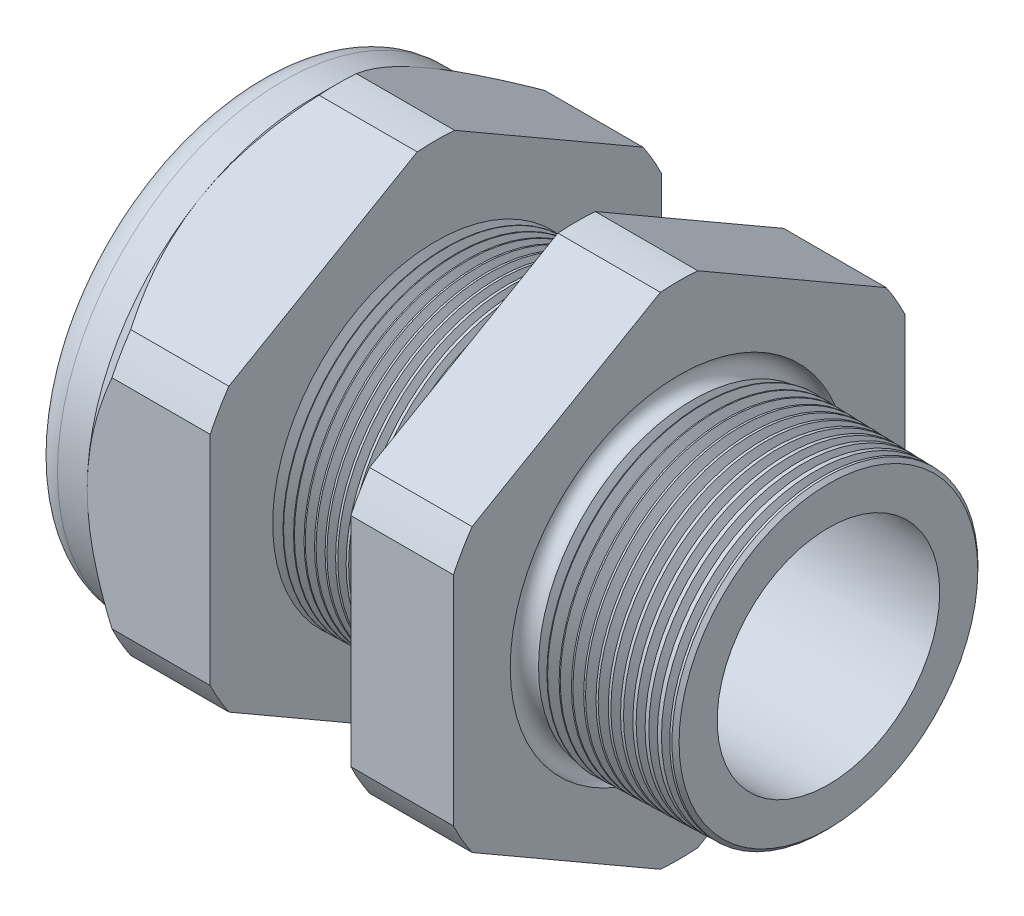
from build123d import *

# Parameters (mm, degrees)
SKETCH12_OUTSIDE_W = 88.514
SKETCH12_OUTSIDE_H = 88.514
CUT_EXTRUDE2_DEPTH = 38.71
FILLET4_R          = 2.032
SKETCH19_OUTSIDE_W = 55.962
SKETCH19_OUTSIDE_H = 59.594
SKETCH19_OUTSIDE_R = 16.51
CUT_EXTRUDE3_DEPTH = 3.99796
CUT_EXTRUDE3_DRAFT = -45
CHAMFER1_SIZE      = 0.260919487
CHAMFER1_SIZE2     = 0.254
SKETCH21_R         = 9.017
PLUG_DEPTH         = 8.89
SKETCH22_R         = 8.763
CUT_EXTRUDE4_DEPTH = 0.508
SKETCH27_R         = 3.683
PLUGHOLES_DEPTH    = 42.402
CIRPATTERN1_COUNT  = 2
LPATTERN1_COUNT    = 14
LPATTERN1_PITCH    = 0.762
LPATTERN2_COUNT    = 12
LPATTERN2_PITCH    = 0.889
SKETCH32_R         = 0.889


with BuildPart() as part:
    # Sketch10 → Revolve2 (revolve)
    with BuildSketch(Plane.XY, mode=Mode.PRIVATE) as revolve2_sk:
        Polygon((-38.862, 9.017), (-25.662, 9.017), (3.048, 8.138202192), (3.048, 11.186202192), (-7.874, 11.472204827), (-7.874, 33.02), (-15.374, 33.02), (-15.374, 11.668599239), (-25.662, 11.938), (-25.662, 33.02), (-34.662, 33.02), (-34.662, 16.51), (-38.862, 16.51), align=None)
    revolve(revolve2_sk.sketch.rotate(Axis((0, 0, 0), (-1, 0, 0)), 90), axis=Axis((0, 0, 0), (-1, 0, 0)))  # turned: the seam where the file's is

    # Sketch12 outside → Cut-Extrude2 (cut, through all)
    with BuildSketch(Plane.ZY.offset(34.662)):
        Rectangle(SKETCH12_OUTSIDE_W, SKETCH12_OUTSIDE_H)
        with BuildLine():
            Line((-1.366648898, 18.27507078), (-15.143351102, 10.321088053))
            ThreePointArc((-15.143351102, 10.321088053), (-15.870868152, 9.16305), (-16.51, 7.953982726))
            Line((-16.51, 7.953982726), (-16.51, -7.953982726))
            ThreePointArc((-16.51, -7.953982726), (-15.870868152, -9.16305), (-15.143351102, -10.321088053))
            Line((-15.143351102, -10.321088053), (-1.366648898, -18.27507078))
            ThreePointArc((-1.366648898, -18.27507078), (0, -18.3261), (1.366648898, -18.27507078))
            Line((1.366648898, -18.27507078), (15.143351102, -10.321088053))
            ThreePointArc((15.143351102, -10.321088053), (15.870868152, -9.16305), (16.51, -7.953982726))
            Line((16.51, -7.953982726), (16.51, 7.953982726))
            ThreePointArc((16.51, 7.953982726), (15.870868152, 9.16305), (15.143351102, 10.321088053))
            Line((15.143351102, 10.321088053), (1.366648898, 18.27507078))
            ThreePointArc((1.366648898, 18.27507078), (0, 18.3261), (-1.366648898, 18.27507078))
        make_face(mode=Mode.SUBTRACT)
    extrude(amount=-CUT_EXTRUDE2_DEPTH, mode=Mode.SUBTRACT)

    # Fillet4
    fillet4_edges = [part.edges().sort_by_distance(p)[0] for p in [
        (-38.862, 0, 16.51),
    ]]
    fillet(fillet4_edges, radius=FILLET4_R)


with BuildPart() as cut_extrude3_tool:
    # Sketch19 outside → Cut-Extrude3 (with draft: the straight prism first)
    with BuildSketch(Plane.ZY.offset(34.662)):
        Rectangle(SKETCH19_OUTSIDE_W, SKETCH19_OUTSIDE_H)
        Circle(SKETCH19_OUTSIDE_R, mode=Mode.SUBTRACT)
    extrude(amount=-CUT_EXTRUDE3_DEPTH)
    # Cut-Extrude3: the draft: its side faces are tilted about the plane it starts from
    cut_extrude3_sides = [cut_extrude3_tool.faces().sort_by_distance(p)[0] for p in [
        (-32.66302, -29.797, 0),
        (-32.66302, 0, 27.981),
        (-32.66302, 29.797, 0),
        (-32.66302, 0, -27.981),
        (-32.66302, 0, -16.51),
    ]]
    draft(cut_extrude3_sides, Plane.ZY.offset(34.662), CUT_EXTRUDE3_DRAFT)


with BuildPart() as part_1:
    add(part.part)

    # Cut-Extrude3: cut by cut_extrude3_tool
    add(cut_extrude3_tool.part, mode=Mode.SUBTRACT)

    # Chamfer1
    chamfer1_edges = [part_1.edges().sort_by_distance(p)[0] for p in [
        (3.048, 0, 11.186202192),
    ]]
    chamfer1_side = [part_1.faces().sort_by_distance(p)[0] for p in [
        (3.048, 0, 8.454595769),
    ]]
    chamfer(chamfer1_edges, length=CHAMFER1_SIZE, length2=CHAMFER1_SIZE2, reference=chamfer1_side[0])

    # Sketch29 → Cut-Revolve1 (revolve, cut)
    with BuildSketch(Plane.XY, mode=Mode.PRIVATE) as cut_revolve1_sk:
        Polygon((-25.662, 11.938), (-24.929016419, 11.918806149), (-25.312130572, 11.293620673), align=None)
    cut_revolve1 = revolve(cut_revolve1_sk.sketch.rotate(Axis((0, 0, 0), (-1, 0, 0)), 90), axis=Axis((0, 0, 0), (-1, 0, 0)), mode=Mode.SUBTRACT)  # turned: the seam where the file's is

    # LPattern1: Cut-Revolve1 ×14
    with Locations(*[(i * LPATTERN1_PITCH, 0, 0) for i in range(1, LPATTERN1_COUNT)]):
        add(cut_revolve1, mode=Mode.SUBTRACT)

    # Sketch30 → Cut-Revolve2 (revolve, cut)
    with BuildSketch(Plane.XY, mode=Mode.PRIVATE) as cut_revolve2_sk:
        Polygon((-7.874, 11.472204827), (-6.994419703, 11.449172206), (-7.454156686, 10.698949635), align=None)
    cut_revolve2 = revolve(cut_revolve2_sk.sketch.rotate(Axis((0, 0, 0), (-1, 0, 0)), 270), axis=Axis((0, 0, 0), (-1, 0, 0)), mode=Mode.SUBTRACT)  # turned: the seam where the file's is

    # LPattern2: Cut-Revolve2 ×12
    with Locations(*[(i * LPATTERN2_PITCH, 0, 0) for i in range(1, LPATTERN2_COUNT)]):
        add(cut_revolve2, mode=Mode.SUBTRACT)

    # Sketch32 → Cut-Revolve3 (revolve, cut)
    with BuildSketch(Plane.XY, mode=Mode.PRIVATE) as cut_revolve3_sk:
        with Locations((-7.747, 11.472204827)):
            Circle(SKETCH32_R)
    revolve(cut_revolve3_sk.sketch.rotate(Axis((0, 0, 0), (-1, 0, 0)), 270), axis=Axis((0, 0, 0), (-1, 0, 0)), mode=Mode.SUBTRACT)  # turned: the seam where the file's is


with BuildPart() as body_2:
    # Sketch21 → plug (new body)
    with BuildSketch(Plane.ZY.offset(38.862)):
        Circle(SKETCH21_R)
    extrude(amount=-PLUG_DEPTH)

    # Sketch22 → Cut-Extrude4 (cut)
    with BuildSketch(Plane.ZY.offset(38.862)):
        Circle(SKETCH22_R)
    extrude(amount=-CUT_EXTRUDE4_DEPTH, mode=Mode.SUBTRACT)

    # Sketch27 → plugholes (cut, through all)
    with BuildSketch(Plane.ZY.offset(38.354)):
        with Locations((-5.065268, 0)):
            Circle(SKETCH27_R)
    plugholes = extrude(amount=-PLUGHOLES_DEPTH, mode=Mode.SUBTRACT)

    # CirPattern1: plugholes ×2 about axis
    cirpattern1_axis = Axis((0, 0, 0), (1, 0, 0))
    for i in range(1, CIRPATTERN1_COUNT):
        add(plugholes.rotate(cirpattern1_axis, i * 360 / CIRPATTERN1_COUNT), mode=Mode.SUBTRACT)


solid = Compound([part_1.part, body_2.part])
